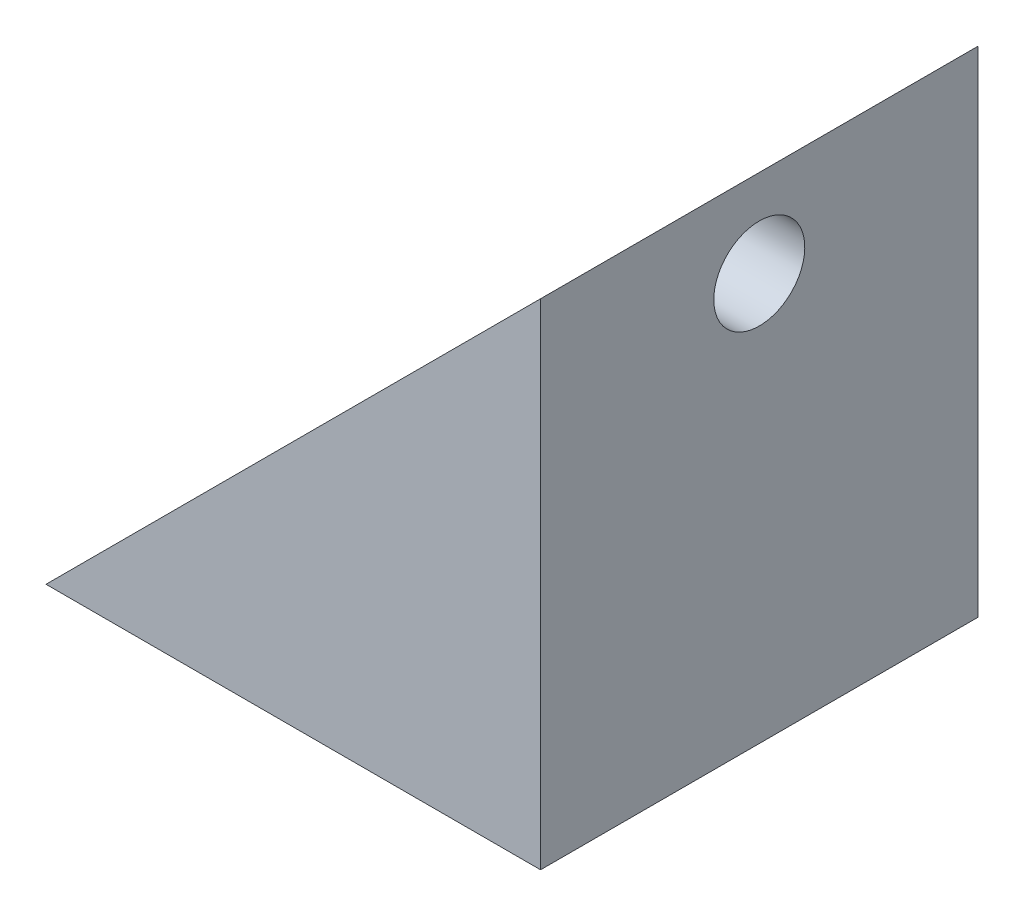
from build123d import *

# Parameters (mm, degrees)
BOSS_EXTRUDE1_DEPTH            = 25
SKETCH2_R                      = 2.6
CUT_EXTRUDE1_DEPTH             = 29.265728709
CUT_EXTRUDE2_REACH             = 30.266
SKETCH3_R                      = 2.6
CUT_EXTRUDE2_DIRECTION_2_DEPTH = 1
CUT_EXTRUDE3_START             = -4
SKETCH5_R                      = 5.5
CUT_EXTRUDE3_DEPTH             = 25.265728709
CUT_EXTRUDE4_START             = -4
SKETCH7_R                      = 5.5
CUT_EXTRUDE4_DEPTH             = 25.265728709


with BuildPart() as part:
    # Sketch1 → Boss-Extrude1 (new body)
    with BuildSketch(Plane.XY):
        Polygon((0, 0), (28.265728709, 28.265728709), (28.265728709, 0), align=None)
    extrude(amount=-BOSS_EXTRUDE1_DEPTH)

    # Sketch2 → Cut-Extrude1 (cut, through all)
    with BuildSketch(Plane.XZ):
        with Locations((5, -12.5)):
            Circle(SKETCH2_R)
    extrude(amount=-CUT_EXTRUDE1_DEPTH, mode=Mode.SUBTRACT)

    # Sketch3 → Cut-Extrude2 (cut, up to next)
    with BuildSketch(Plane(origin=(28.265728709, 0, 0), x_dir=(0, 0, -1), z_dir=(1, 0, 0)), mode=Mode.PRIVATE) as cut_extrude2_sk1:
        with Locations((12.5, 23.265728709)):
            Circle(SKETCH3_R)
    cut_extrude2_tool1 = extrude(cut_extrude2_sk1.sketch, amount=-CUT_EXTRUDE2_REACH, mode=Mode.PRIVATE) & part.part
    add(cut_extrude2_tool1.solids().sort_by_distance((28.265729, 23.265729, -12.5))[0], mode=Mode.SUBTRACT)

    # Sketch3 → Cut-Extrude2 direction 2 (cut)
    with BuildSketch(Plane(origin=(28.265728709, 0, 0), x_dir=(0, 0, -1), z_dir=(1, 0, 0))):
        with Locations((12.5, 23.265728709)):
            Circle(SKETCH3_R)
    extrude(amount=CUT_EXTRUDE2_DIRECTION_2_DEPTH, mode=Mode.SUBTRACT)

    # Sketch5 → Cut-Extrude3 (cut, through all)
    with BuildSketch(Plane(origin=(28.265728709, 0, 0), x_dir=(0, 0, -1), z_dir=(1, 0, 0)).offset(CUT_EXTRUDE3_START)):
        with Locations((12.5, 23.265728709)):
            Circle(SKETCH5_R)
    extrude(amount=-CUT_EXTRUDE3_DEPTH, mode=Mode.SUBTRACT)

    # Sketch7 → Cut-Extrude4 (cut, through all)
    with BuildSketch(Plane.XZ.offset(CUT_EXTRUDE4_START)):
        with Locations((5, -12.5)):
            Circle(SKETCH7_R)
    extrude(amount=-CUT_EXTRUDE4_DEPTH, mode=Mode.SUBTRACT)


solid = part.part
